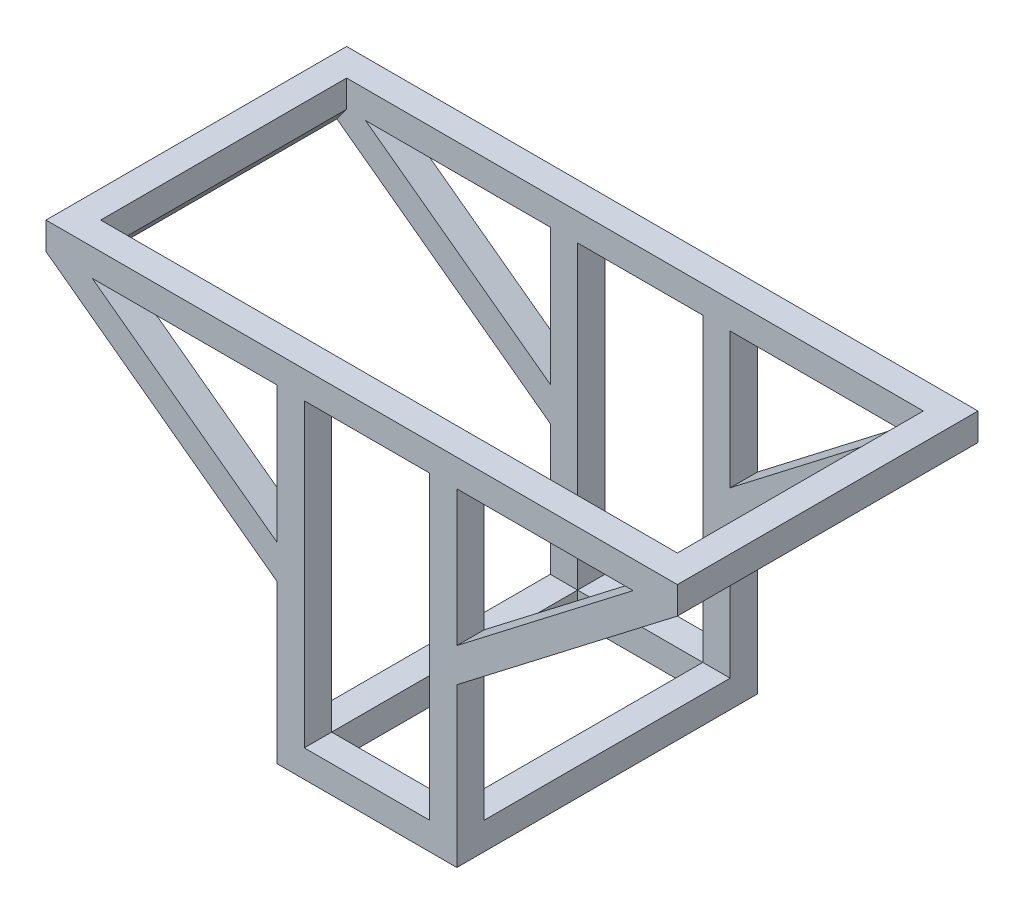
from build123d import *

# Parameters (mm, degrees)
SKETCH3_W           = 45.820005247
SKETCH3_H           = 110
EXTRUDE1_DEPTH      = 110
SKETCH5_W           = 90
SKETCH5_H           = 37.77
CUT_EXTRUDE1_DEPTH  = 72
SKETCH6_W           = 45.820005247
SKETCH6_H           = 90
CUT_EXTRUDE3_DEPTH  = 130
SKETCH8_W           = 211
SKETCH8_H           = 90
CUT_EXTRUDE4_DEPTH  = 20
SKETCH9_W           = 91.800610731
SKETCH9_H           = 90
CUT_EXTRUDE6_DEPTH  = 10
SKETCH10_W          = 90
SKETCH10_H          = 72.23
CUT_EXTRUDE9_DEPTH  = 10
SKETCH11_W          = 103.619303527
SKETCH11_H          = 90
CUT_EXTRUDE11_DEPTH = 20
SKETCH12_W          = 90
SKETCH12_H          = 82.03288143
CUT_EXTRUDE13_DEPTH = 20


with BuildPart() as part:
    # Sketch3 → Extrude1 (new body)
    with BuildSketch(Plane.XY):
        Polygon((-115.5, 130), (115.5, 130), (115.5, 120), (34.820005247, 57.918579334), (34.820005247, 0), (-31, 0), (-31, 57.77), (-115.5, 120), align=None)
        Polygon((-31, 120), (-31, 70.171133991), (-98.581267218, 120), align=None, mode=Mode.SUBTRACT)
        Polygon((34.820005247, 70.319713325), (34.820005247, 120), (99.331172327, 120), align=None, mode=Mode.SUBTRACT)
        with Locations((1.910002624, 65)):
            Rectangle(SKETCH3_W, SKETCH3_H, mode=Mode.SUBTRACT)
    extrude(amount=EXTRUDE1_DEPTH)

    # Sketch5 → Cut-Extrude1 (cut)
    with BuildSketch(Plane.ZY.offset(31)):
        with Locations((55, 28.885)):
            Rectangle(SKETCH5_W, SKETCH5_H)
    extrude(amount=-CUT_EXTRUDE1_DEPTH, mode=Mode.SUBTRACT)

    # Sketch6 → Cut-Extrude3 (cut)
    with BuildSketch(Plane(origin=(0, 0, 0), x_dir=(1, 0, 0), z_dir=(0, 1, 0))):
        with Locations((1.910002624, -55)):
            Rectangle(SKETCH6_W, SKETCH6_H)
    extrude(amount=CUT_EXTRUDE3_DEPTH, mode=Mode.SUBTRACT)

    # Sketch8 → Cut-Extrude4 (cut)
    with BuildSketch(Plane(origin=(0, 130, 0), x_dir=(1, 0, 0), z_dir=(0, 1, 0))):
        with Locations((0, -55)):
            Rectangle(SKETCH8_W, SKETCH8_H)
    extrude(amount=-CUT_EXTRUDE4_DEPTH, mode=Mode.SUBTRACT)

    # Sketch9 → Cut-Extrude6 (cut)
    with BuildSketch(Plane(origin=(-15.043239393, 19.549946865, 0), x_dir=(0.792529575, 0.60983348, 0), z_dir=(0.60983348, -0.792529575, 0))):
        with Locations((108.816878092, 55)):
            Rectangle(SKETCH9_W, SKETCH9_H)
    extrude(amount=-CUT_EXTRUDE6_DEPTH, mode=Mode.SUBTRACT)

    # Sketch10 → Cut-Extrude9 (cut)
    with BuildSketch(Plane(origin=(34.820005247, 0, 0), x_dir=(0, 0, -1), z_dir=(1, 0, 0))):
        with Locations((-55, 83.885)):
            Rectangle(SKETCH10_W, SKETCH10_H)
    extrude(amount=-CUT_EXTRUDE9_DEPTH, mode=Mode.SUBTRACT)

    # Sketch11 → Cut-Extrude11 (cut)
    with BuildSketch(Plane(origin=(16.683281999, 22.653661079, 0), x_dir=(0.805206703, -0.592994238, 0), z_dir=(-0.592994238, -0.805206703, 0))):
        with Locations((-104.356929468, 55)):
            Rectangle(SKETCH11_W, SKETCH11_H)
    extrude(amount=-CUT_EXTRUDE11_DEPTH, mode=Mode.SUBTRACT)

    # Sketch12 → Cut-Extrude13 (cut)
    with BuildSketch(Plane.ZY.offset(31)):
        with Locations((55, 88.786440715)):
            Rectangle(SKETCH12_W, SKETCH12_H)
    extrude(amount=-CUT_EXTRUDE13_DEPTH, mode=Mode.SUBTRACT)


solid = part.part
